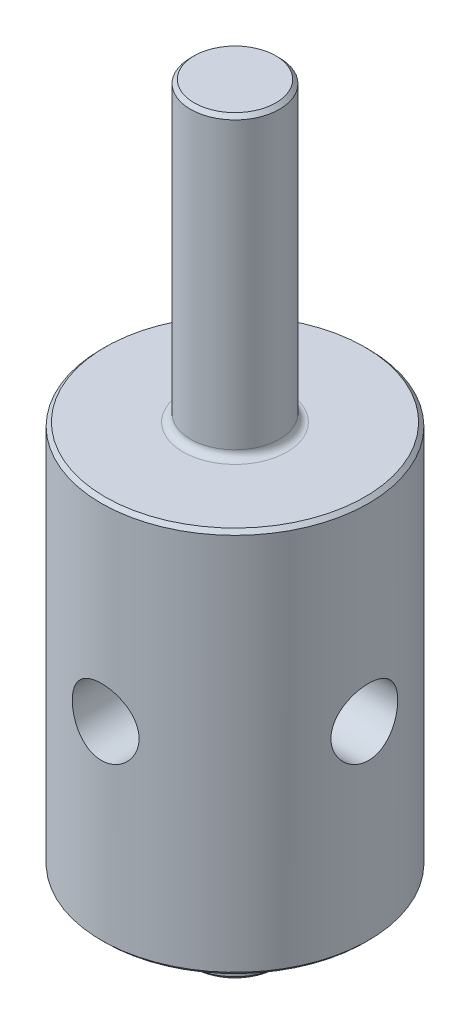
from build123d import *

# Parameters (mm, degrees)
FURO_DE_DI_METRO_4_5_4_5_2_D = 4.5
ESBO_O8_W                    = 2.25
ESBO_O8_H                    = 9
FILLET1_R                    = 0.5
CHAMFER1_SIZE                = 0.25
CHAMFER4_SIZE                = 0.25


with BuildPart() as part:
    # Esboço1 → Revolução1 (revolve)
    with BuildSketch(Plane.XY):
        Polygon((0, 33), (3, 33), (3, 13), (9, 13), (9, -13), (3, -13), (3, -17.5), (0, -17.5), (0, 0), align=None)
    revolve(axis=Axis((0, 0, 0), (0, 1, 0)))

    # Furo de diâmetro Ø4.5 (4.5)2 (through all)
    with Locations(Plane(origin=(-9, 0, 0), x_dir=(0, 0, -1), z_dir=(-1, 0, 0))):
        with Locations((0, 0)):
            Hole(FURO_DE_DI_METRO_4_5_4_5_2_D / 2)

    # Esboço8 → Furo de diâmetro Ø4.5 (4.5)1 (revolve, cut)
    with BuildSketch(Plane(origin=(0, 0, 9), x_dir=(0, -1, 0), z_dir=(1, 0, 0))):
        with Locations((1.125, 4.5)):
            Rectangle(ESBO_O8_W, ESBO_O8_H)
    revolve(axis=Axis((0, 0, 15.35), (0, 0, -1)), mode=Mode.SUBTRACT)

    # Fillet1
    fillet1_edges = [part.edges().sort_by_distance(p)[0] for p in [
        (-3, -13, 0),
        (-3, 13, 0),
    ]]
    fillet(fillet1_edges, radius=FILLET1_R)

    # Chamfer1
    chamfer1_edges = [part.edges().sort_by_distance(p)[0] for p in [
        (-3, -17.5, 0),
        (-3, 33, 0),
    ]]
    chamfer(chamfer1_edges, length=CHAMFER1_SIZE)

    # Chamfer4
    chamfer4_edges = [part.edges().sort_by_distance(p)[0] for p in [
        (-9, -13, 0),
        (-9, 13, 0),
    ]]
    chamfer(chamfer4_edges, length=CHAMFER4_SIZE)


solid = part.part
